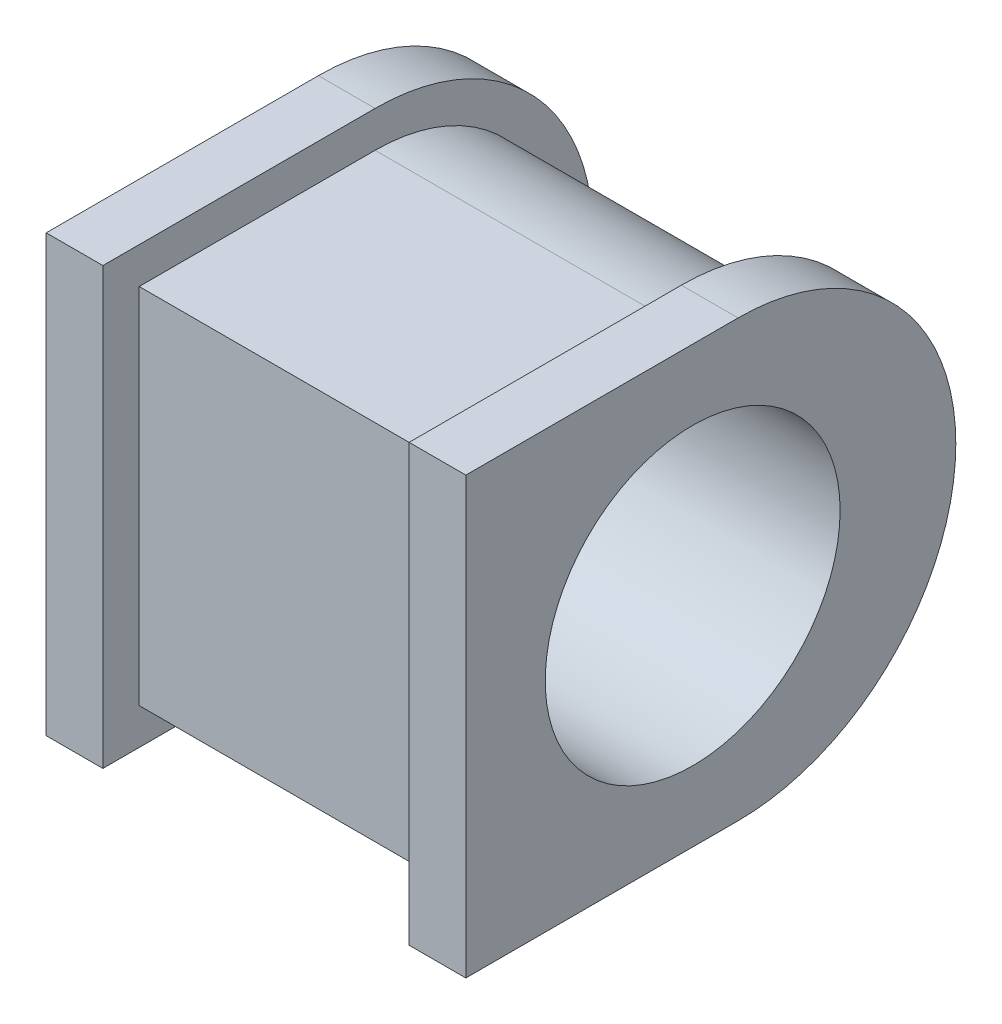
from build123d import *

# Parameters (mm, degrees)
BOSS_EXTRUDE1_DEPTH = 80
BOSS_EXTRUDE2_DEPTH = 12.5
CUT_EXTRUDE1_REACH  = 94.5
SKETCH3_R           = 32.5


with BuildPart() as part:
    # Sketch1 → Boss-Extrude1 (new body)
    with BuildSketch(Plane(origin=(0, 0, 0), x_dir=(0, 0, -1), z_dir=(1, 0, 0))):
        with BuildLine():
            Line((0, 0), (52, 0))
            ThreePointArc((52, 0), (92, 40), (52, 80))
            Line((52, 80), (0, 80))
            Line((0, 80), (0, 0))
        make_face()
    extrude(amount=BOSS_EXTRUDE1_DEPTH)

    # Sketch2 → Boss-Extrude2 (add)
    with BuildSketch(Plane(origin=(80, 0, 0), x_dir=(0, 0, -1), z_dir=(1, 0, 0))):
        with BuildLine():
            Line((-8, 88), (-8, -8))
            Line((-8, -8), (52, -8))
            ThreePointArc((52, -8), (100, 40), (52, 88))
            Line((52, 88), (-8, 88))
        make_face()
    boss_extrude2 = extrude(amount=BOSS_EXTRUDE2_DEPTH)

    # Mirror1: Boss-Extrude2 across plane
    add(boss_extrude2.mirror(Plane(origin=(46.25, 0, 0), x_dir=(0, 0, 1), z_dir=(1, 0, 0))))

    # Sketch3 → Cut-Extrude1 (cut, up to next)
    with BuildSketch(Plane(origin=(92.5, 0, 0), x_dir=(0, 0, -1), z_dir=(1, 0, 0)), mode=Mode.PRIVATE) as cut_extrude1_sk1:
        with Locations((42, 40)):
            Circle(SKETCH3_R)
    cut_extrude1_tool1 = extrude(cut_extrude1_sk1.sketch, amount=-CUT_EXTRUDE1_REACH, mode=Mode.PRIVATE) & part.part
    add(cut_extrude1_tool1.solids().sort_by_distance((92.5, 40, -42))[0], mode=Mode.SUBTRACT)


solid = part.part
